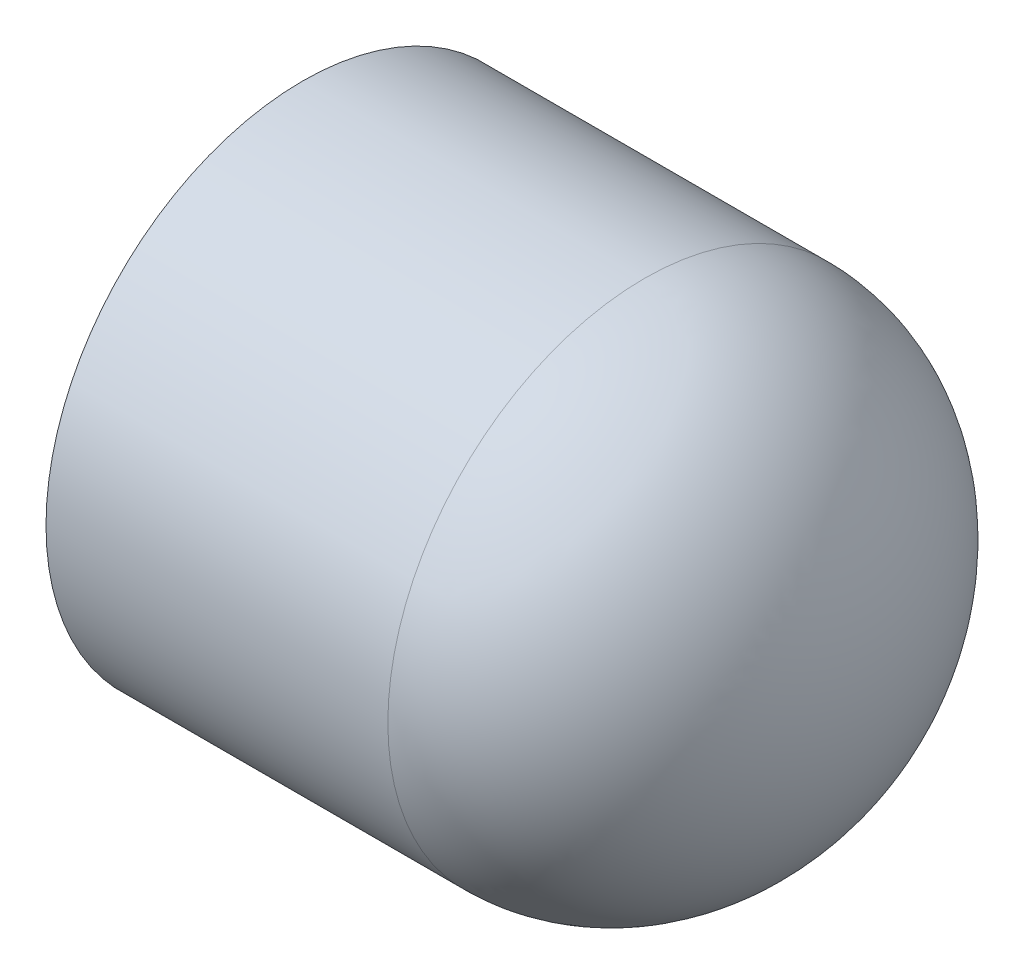
from build123d import *


with BuildPart() as part:
    # Sketch1 → Revolve1 (revolve)
    with BuildSketch(Plane.XY):
        with BuildLine():
            Line((11.7221, 0), (14.7193, 0))
            add(Edge.make_bspline(
                [(3.4163, -13.6144), (14.7193, -13.6144), (14.7193, 0)],
                knots=[3.141592654, 3.141592654, 3.141592654, 4.71238898, 4.71238898, 4.71238898], degree=2, weights=[1, 0.707106781, 1]))
            Line((3.4163, -13.6144), (-14.7193, -13.6144))
            Line((-14.7193, -13.6144), (-14.7193, -10.7696))
            Line((-14.7193, -10.7696), (3.4163, -10.6172))
            add(Edge.make_bspline(
                [(3.4163, -10.6172), (11.7221, -10.6172), (11.7221, 0)],
                knots=[0, 0, 0, 1.570796327, 1.570796327, 1.570796327], degree=2, weights=[1, 0.707106781, 1]))
        make_face()
    revolve(axis=Axis((-14.7193, 0, 0), (1, 0, 0)))


solid = part.part
